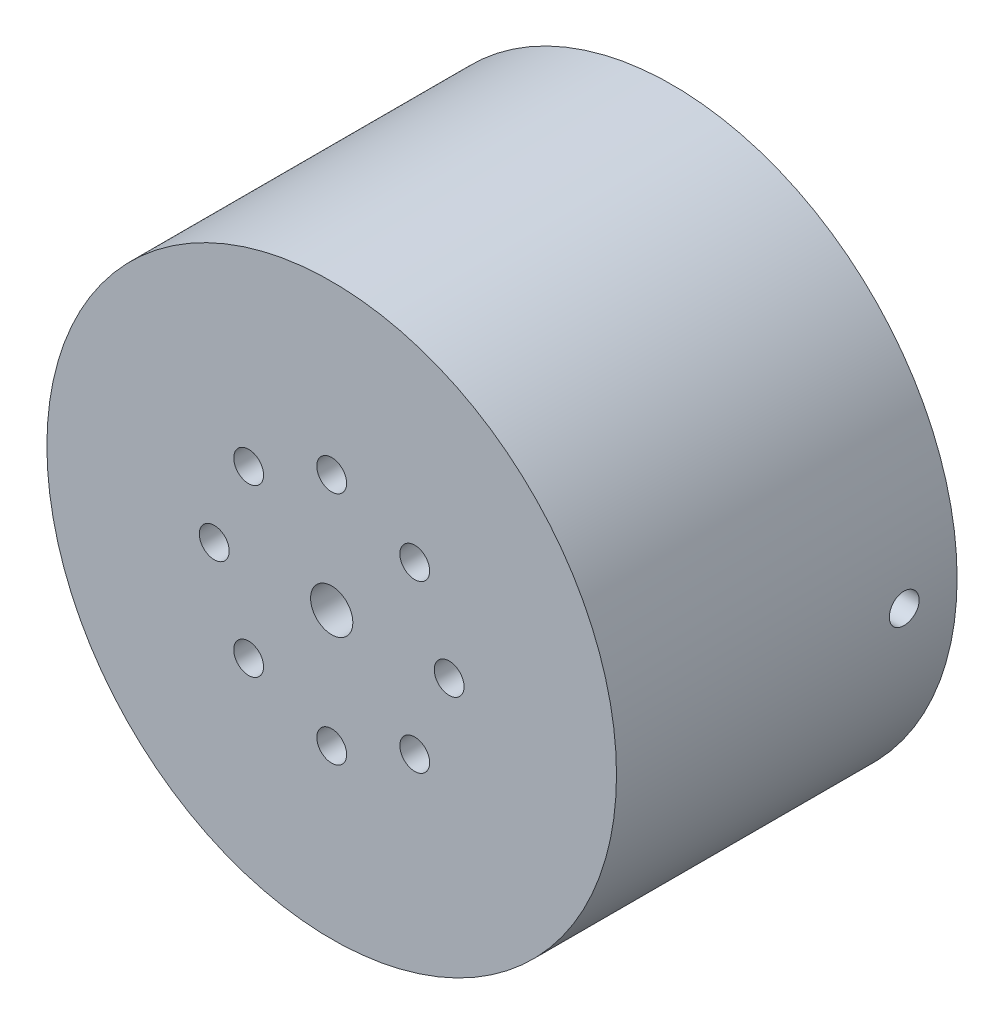
from build123d import *

# Parameters (mm, degrees)
SKETCH1_R           = 24.25
SKETCH1_R_2         = 14.25
BOSS_EXTRUDE1_DEPTH = 25
SKETCH2_R           = 24.25
SKETCH2_R_2         = 1.8
BOSS_EXTRUDE2_DEPTH = 4
SKETCH3_W           = 5
SKETCH3_H           = 8.89
CUT_EXTRUDE1_DEPTH  = 11
SKETCH4_R           = 1.27
CUT_EXTRUDE2_DEPTH  = 39
FILLET1_R           = 4
SKETCH5_R           = 1.27
CUT_EXTRUDE3_DEPTH  = 78


with BuildPart() as part:
    # Sketch1 → Boss-Extrude1 (new body)
    with BuildSketch(Plane.XY):
        Circle(SKETCH1_R)
        Circle(SKETCH1_R_2, mode=Mode.SUBTRACT)
    extrude(amount=BOSS_EXTRUDE1_DEPTH)

    # Sketch2 → Boss-Extrude2 (add)
    with BuildSketch(Plane.XY.offset(25)):
        Circle(SKETCH2_R)
        Circle(SKETCH2_R_2, mode=Mode.SUBTRACT)
    extrude(amount=BOSS_EXTRUDE2_DEPTH)

    # Sketch3 → Cut-Extrude1 (cut)
    with BuildSketch(Plane(origin=(0, 0, 0), x_dir=(-1, 0, 0), z_dir=(0, 0, -1))):
        with Locations((-18.5, 0)):
            Rectangle(SKETCH3_W, SKETCH3_H)
        with Locations((18.5, 0)):
            Rectangle(SKETCH3_W, SKETCH3_H)
    extrude(amount=-CUT_EXTRUDE1_DEPTH, mode=Mode.SUBTRACT)

    # Sketch4 → Cut-Extrude2 (cut, symmetric)
    with BuildSketch(Plane(origin=(0, 0, 0), x_dir=(0, 0, -1), z_dir=(1, 0, 0))):
        with Locations((-4.5, 0)):
            Circle(SKETCH4_R)
    extrude(amount=CUT_EXTRUDE2_DEPTH, both=True, mode=Mode.SUBTRACT)

    # Fillet1
    fillet1_edges = [part.edges().sort_by_distance(p)[0] for p in [
        (-14.25, 0, 25),
    ]]
    fillet(fillet1_edges, radius=FILLET1_R)

    # Sketch5 → Cut-Extrude3 (cut)
    with BuildSketch(Plane.XY.offset(29)):
        with Locations((0, 10)):
            Circle(SKETCH5_R)
        with Locations((7.071067812, 7.071067812)):
            Circle(SKETCH5_R)
        with Locations((10, 0)):
            Circle(SKETCH5_R)
        with Locations((7.071067812, -7.071067812)):
            Circle(SKETCH5_R)
        with Locations((0, -10)):
            Circle(SKETCH5_R)
        with Locations((-7.071067812, -7.071067812)):
            Circle(SKETCH5_R)
        with Locations((-10, 0)):
            Circle(SKETCH5_R)
        with Locations((-7.071067812, 7.071067812)):
            Circle(SKETCH5_R)
    extrude(amount=-CUT_EXTRUDE3_DEPTH, mode=Mode.SUBTRACT)


solid = part.part
